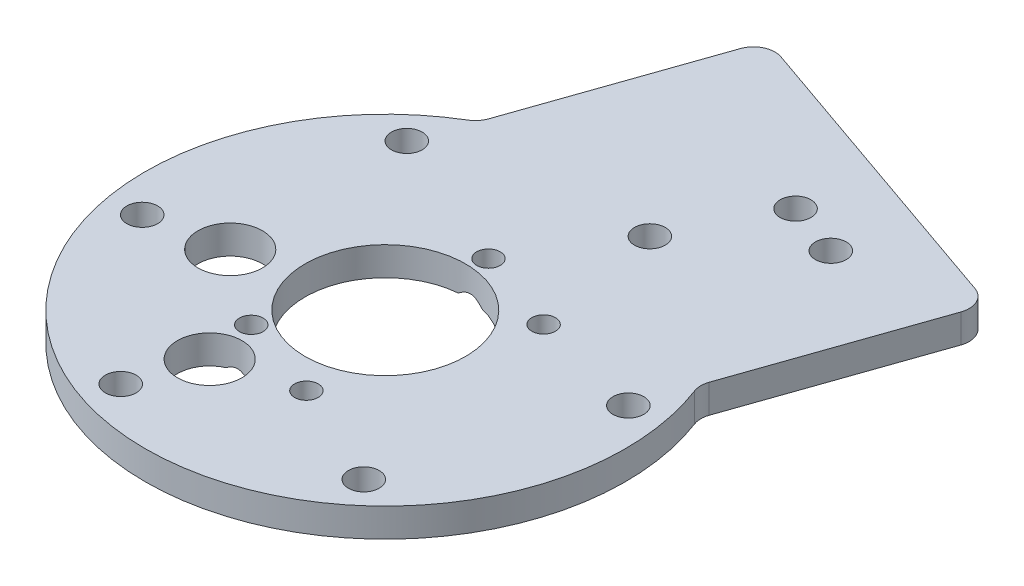
from build123d import *

# Parameters (mm, degrees)
SKETCH_1_R                = 33.5
EXTRUDE_1_DEPTH           = 4
SKETCH_2_R                = 2.15
CUT_EXTRUDE_1_DEPTH       = 24
SKETCH_3_R                = 4.5
CUT_EXTRUDE_2_DEPTH       = 5
SKETCH_4_R                = 11.2
CUT_EXTRUDE_3_DEPTH       = 5
HOLE_WIZARD_1_D           = 3.3
HOLE_WIZARD_1_CSINK_D     = 6
HOLE_WIZARD_1_CSINK_ANGLE = 90
SKETCH_9_R                = 2.15
SKETCH_9_R_2              = 4.5
SKETCH_9_R_3              = 3
EXTRUDE_2_DEPTH           = 4
SKETCH_10_R               = 2.15
CUT_EXTRUDE_4_DEPTH       = 4
FILLET_1_R                = 3


with BuildPart() as part:
    # 草图1 → 凸台-拉伸1 (new body)
    with BuildSketch(Plane(origin=(0, 0, 0), x_dir=(1, 0, 0), z_dir=(0, 1, 0))):
        Circle(SKETCH_1_R)
    extrude(amount=EXTRUDE_1_DEPTH)

    # 草图2 → 切除-拉伸1 (cut)
    with BuildSketch(Plane(origin=(0, 4, 0), x_dir=(1, 0, 0), z_dir=(0, 1, 0))):
        with Locations((-18.950679053, 21.951577698)):
            Circle(SKETCH_2_R)
        with Locations((9.535284413, 27.387558328)):
            Circle(SKETCH_2_R)
        with Locations((28.485963466, 5.43598063)):
            Circle(SKETCH_2_R)
        with Locations((18.950679053, -21.951577698)):
            Circle(SKETCH_2_R)
        with Locations((-9.535284413, -27.387558328)):
            Circle(SKETCH_2_R)
        with Locations((-28.485963466, -5.43598063)):
            Circle(SKETCH_2_R)
    extrude(amount=-CUT_EXTRUDE_1_DEPTH, mode=Mode.SUBTRACT)

    # 草图3 → 切除-拉伸2 (cut, through all)
    with BuildSketch(Plane(origin=(0, 4, 0), x_dir=(1, 0, 0), z_dir=(0, 1, 0))):
        with Locations((-18.172080142, -3.467780747)):
            Circle(SKETCH_3_R)
        with Locations((-6.329456033, -18.179672338)):
            Circle(SKETCH_3_R)
    extrude(amount=-CUT_EXTRUDE_2_DEPTH, mode=Mode.SUBTRACT)

    # 草图4 → 切除-拉伸3 (cut, through all)
    with BuildSketch(Plane(origin=(0, 4, 0), x_dir=(1, 0, 0), z_dir=(0, 1, 0))):
        Circle(SKETCH_4_R)
    extrude(amount=-CUT_EXTRUDE_3_DEPTH, mode=Mode.SUBTRACT)

    # 孔1 (through all)
    with Locations(Plane(origin=(12.774024908, 0, -9.317955122), x_dir=(0, 0, -1), z_dir=(0, -1, 0))):
        with Locations((0, 0), (4.110036385, -11.804982038), (-24.554362639, -8.548875681), (-20.444326254, -20.353857719)):
            CounterSinkHole(HOLE_WIZARD_1_D / 2, HOLE_WIZARD_1_CSINK_D / 2, counter_sink_angle=HOLE_WIZARD_1_CSINK_ANGLE)

    # 草图9 → 凸台-拉伸2 (add)
    with BuildSketch(Plane.XZ):
        with BuildLine():
            ThreePointArc((30.94197409, -12.839168175), (11.014897512, -31.637351862), (-16.277954062, -29.279313714))
            Line((-16.277954062, -29.279313714), (-5.854606893, -59.217595173))
            Line((-5.854606893, -59.217595173), (41.365321259, -42.777449634))
            Line((41.365321259, -42.777449634), (30.94197409, -12.839168175))
        make_face()
        with BuildLine():
            Line((-19.548240775, -19.886288375), (-23.609964076, -8.22007277))
            Line((-23.609964076, -8.22007277), (-10.577263906, -3.682592601))
            ThreePointArc((-10.577263906, -3.682592601), (-10.882752845, 2.646826497), (-7.704540242, 8.128964243))
            ThreePointArc((-7.704540242, 8.128964243), (-10.570999096, 10.896318406), (-8.161427671, 14.069455809))
            ThreePointArc((-8.161427671, 14.069455809), (-5.543963925, 22.610586708), (-6.021999809, 13.690187884))
            ThreePointArc((-6.021999809, 13.690187884), (-4.757437603, 12.143270974), (-4.744786266, 10.145294638))
            ThreePointArc((-4.744786266, 10.145294638), (4.352709301, 10.319589223), (10.577263906, 3.682592601))
            Line((10.577263906, 3.682592601), (23.609964076, 8.22007277))
            Line((23.609964076, 8.22007277), (27.671687377, -3.446142835))
            ThreePointArc((27.671687377, -3.446142835), (29.684255252, -3.650876488), (30.635963466, -5.43598063))
            ThreePointArc((30.635963466, -5.43598063), (30.204575944, -6.727828589), (29.083525188, -7.501269953))
            Line((29.083525188, -7.501269953), (30.94197409, -12.839168175))
            ThreePointArc((30.94197409, -12.839168175), (32.854270134, -6.545756946), (33.5, 0))
            ThreePointArc((33.5, 0), (-16.984383105, 28.875261566), (-16.277954062, -29.279313714))
            Line((-16.277954062, -29.279313714), (-18.136402964, -23.941415493))
            ThreePointArc((-18.136402964, -23.941415493), (-20.981135964, -22.658503956), (-19.548240775, -19.886288375))
        make_face()
        with Locations((-28.485963466, 5.43598063)):
            Circle(SKETCH_9_R, mode=Mode.SUBTRACT)
        with Locations((-18.172080142, 3.467780747)):
            Circle(SKETCH_9_R_2, mode=Mode.SUBTRACT)
        with Locations((-9.535284413, 27.387558328)):
            Circle(SKETCH_9_R, mode=Mode.SUBTRACT)
        with Locations((4.225149227, 15.236407517)):
            Circle(SKETCH_9_R_3, mode=Mode.SUBTRACT)
        with Locations((18.950679053, 21.951577698)):
            Circle(SKETCH_9_R, mode=Mode.SUBTRACT)
    extrude(amount=-EXTRUDE_2_DEPTH)

    # 草图10 → 切除-拉伸4 (cut)
    with BuildSketch(Plane.XZ):
        with Locations((16.356125201, -40.895930952)):
            Circle(SKETCH_10_R)
        with Locations((23.911313705, -38.265507665)):
            Circle(SKETCH_10_R)
    extrude(amount=-CUT_EXTRUDE_4_DEPTH, mode=Mode.SUBTRACT)

    # 圆角1
    fillet_1_edges = [part.edges().sort_by_distance(p)[0] for p in [
        (30.94197409, 2, -12.839168175),
        (-16.277954062, 2, -29.279313714),
        (-5.854606893, 2, -59.217595173),
        (41.365321259, 2, -42.777449634),
    ]]
    fillet(fillet_1_edges, radius=FILLET_1_R)


solid = part.part
